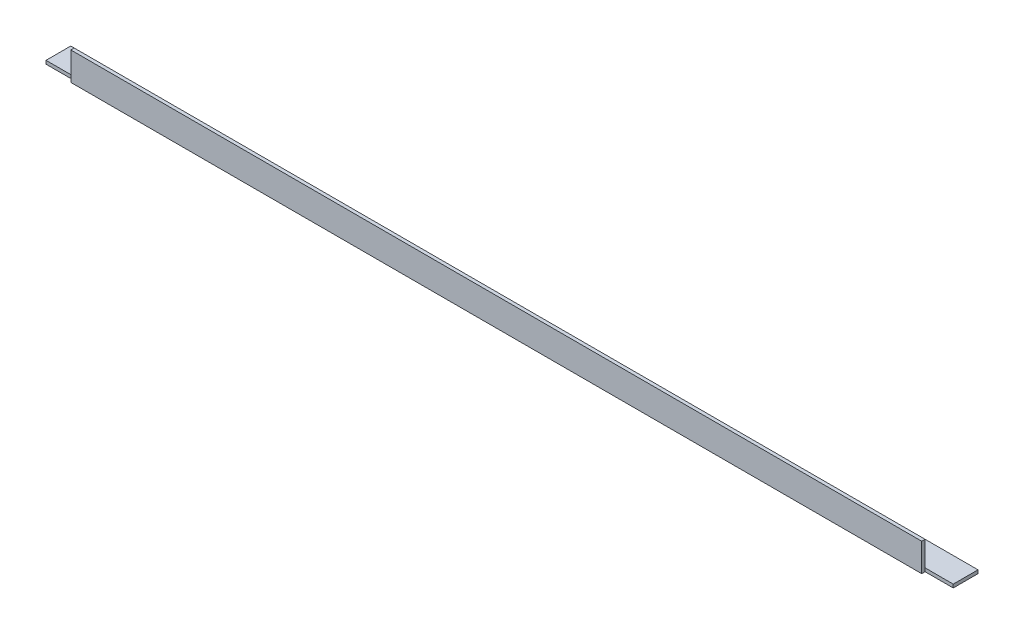
from build123d import *

# Parameters (mm, degrees)
EXTRUDE_1_DEPTH     = 806
SKETCH_2_W          = 25
SKETCH_2_H          = 3
CUT_EXTRUDE_1_DEPTH = 26


with BuildPart() as part:
    # Эскиз1 → Вытянуть-Тонкостенный1 (new body)
    with BuildSketch(Plane(origin=(0, 0, 0), x_dir=(0, 0, -1), z_dir=(1, 0, 0))):
        Polygon((0, 25), (0, 0), (25, 0), (25, 3), (3, 3), (3, 25), align=None)
    extrude(amount=EXTRUDE_1_DEPTH)

    # Эскиз2 → Вырез-Вытянуть1 (cut, through all)
    with BuildSketch(Plane.XZ):
        with Locations((793.5, -1.5)):
            Rectangle(SKETCH_2_W, SKETCH_2_H)
        with Locations((12.5, -1.5)):
            Rectangle(SKETCH_2_W, SKETCH_2_H)
    extrude(amount=-CUT_EXTRUDE_1_DEPTH, mode=Mode.SUBTRACT)


solid = part.part
